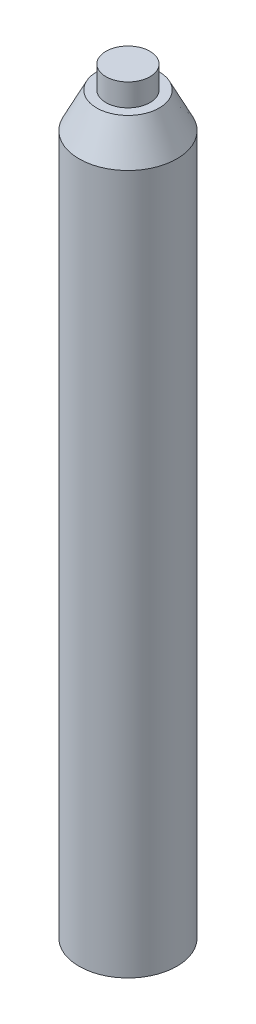
from build123d import *

# Parameters (mm, degrees)
F_6_0_204_DIAMETER_HOLE1_D     = 5.1816
F_6_0_204_DIAMETER_HOLE1_DEPTH = 10
F_6_0_204_DIAMETER_HOLE1_TIP   = 1.556709692


with BuildPart() as part:
    # Sketch1 → Revolve1 (revolve)
    with BuildSketch(Plane.XY):
        Polygon((0, 0), (-5.55, 0), (-5.55, 79.37), (-3.55, 83.37), (-2.5, 83.37), (-2.5, 85.92), (0, 85.92), align=None)
    revolve(axis=Axis((0, 90.216, 0), (0, -1, 0)))

    # #6 (0.204) Diameter Hole1
    with Locations(Plane.XZ):
        with Locations((0, 0)):
            Hole(F_6_0_204_DIAMETER_HOLE1_D / 2, depth=F_6_0_204_DIAMETER_HOLE1_DEPTH)
            with Locations((0, 0, -(F_6_0_204_DIAMETER_HOLE1_DEPTH + F_6_0_204_DIAMETER_HOLE1_TIP / 2))):  # 118° drill point
                Cone(0, F_6_0_204_DIAMETER_HOLE1_D / 2, F_6_0_204_DIAMETER_HOLE1_TIP, mode=Mode.SUBTRACT)


solid = part.part
